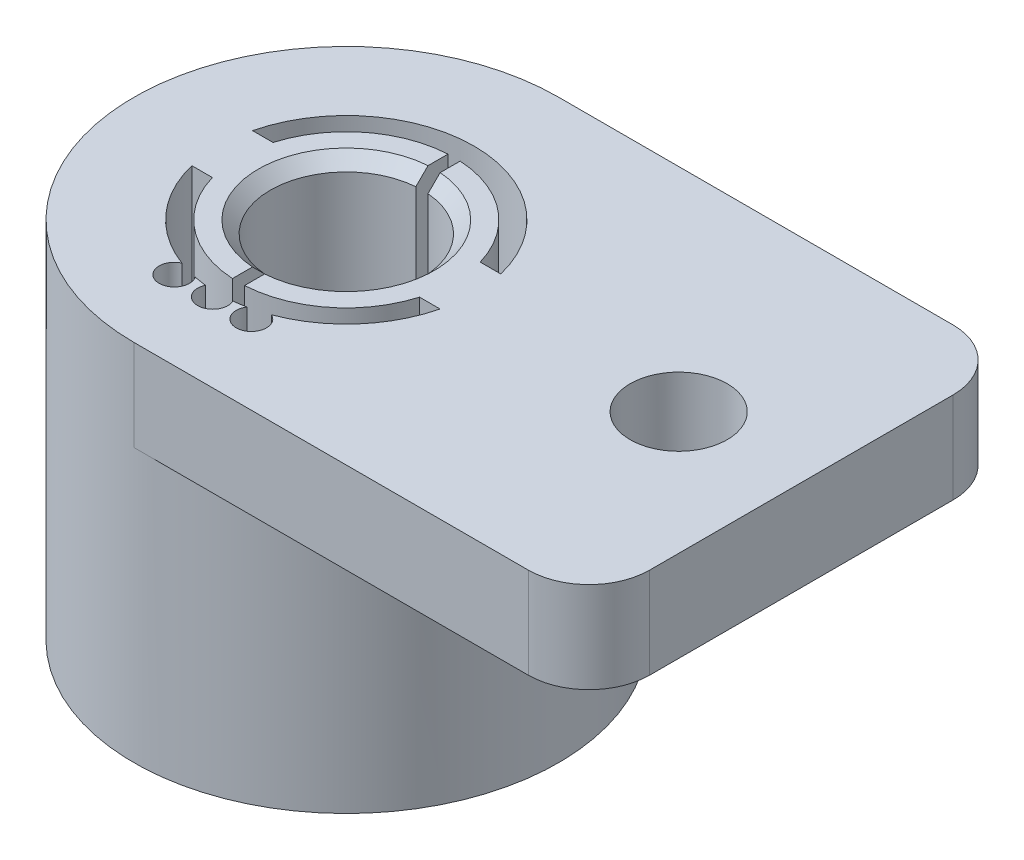
from build123d import *

# Parameters (mm, degrees)
SKETCH_1_R                  = 7
EXTRUDE_1_DEPTH             = 10
EXTRUDE_2_DEPTH             = 3
SKETCH_4_R                  = 2.5
CUT_EXTRUDE_1_DEPTH         = 1
CUT_EXTRUDE_1_DEPTH_BACK    = 14
SKETCH_6_R                  = 7
SKETCH_6_R_2                = 5.585510808
CUT_EXTRUDE_3_DEPTH         = 1
CUT_EXTRUDE_6_DEPTH         = 1
CUT_EXTRUDE_6_DEPTH_BACK    = 14
SKETCH_8_R                  = 0.5
CUT_EXTRUDE_1254_DEPTH      = 1
CUT_EXTRUDE_1254_DEPTH_BACK = 14
SKETCH_9_W                  = 4.5
SKETCH_9_H                  = 1.993168192
TSSOP_DEPTH                 = 2
FILLET_1_R                  = 2
SKETCH_10_R                 = 1.6
CUT_EXTRUDE_9_DEPTH         = 11
CUT_EXTRUDE_9_DEPTH_BACK    = 4
SKETCH_11_R                 = 4.785510808
CUT_EXTRUDE_10_DEPTH        = 0.5
CHAMFER_1_SIZE              = 0.4
CHAMFER_2_SIZE              = 0.4
CHAMFER_3_SIZE              = 0.4
CHAMFER_4_SIZE              = 0.4


with BuildPart() as part:
    # Эскиз1 → Бобышка-Вытянуть1 (new body)
    with BuildSketch(Plane(origin=(0, 0, 0), x_dir=(1, 0, 0), z_dir=(0, 1, 0))):
        Circle(SKETCH_1_R)
    extrude(amount=EXTRUDE_1_DEPTH)

    # Эскиз3 → Бобышка-Вытянуть2 (add)
    with BuildSketch(Plane(origin=(0, 10, 0), x_dir=(1, 0, 0), z_dir=(0, 1, 0))):
        with BuildLine():
            Line((0, 7), (15, 7))
            Line((15, 7), (15, -7))
            Line((15, -7), (0, -7))
            ThreePointArc((0, -7), (-7, 0), (0, 7))
        make_face()
    extrude(amount=EXTRUDE_2_DEPTH)

    # Эскиз4 → Вырез-Вытянуть1 (cut, two sides)
    with BuildSketch(Plane.XZ) as cut_extrude_1_sk:
        Circle(SKETCH_4_R)
    extrude(amount=CUT_EXTRUDE_1_DEPTH, mode=Mode.SUBTRACT)
    extrude(cut_extrude_1_sk.sketch, amount=-CUT_EXTRUDE_1_DEPTH_BACK, mode=Mode.SUBTRACT)

    # Эскиз6 → Вырез-Вытянуть3 (cut)
    with BuildSketch(Plane.XZ):
        Circle(SKETCH_6_R)
        Circle(SKETCH_6_R_2, mode=Mode.SUBTRACT)
    extrude(amount=-CUT_EXTRUDE_3_DEPTH, mode=Mode.SUBTRACT)

    # Эскиз7 → Вырез-Вытянуть6 (cut, two sides)
    with BuildSketch(Plane.XZ) as cut_extrude_6_sk:
        with BuildLine():
            Line((3.414540389, 1), (4.09167532, 1))
            ThreePointArc((4.09167532, 1), (0, 4.212102435), (-4.09167532, 1))
            Line((-4.09167532, 1), (-3.414540389, 1))
            ThreePointArc((-3.414540389, 1), (-2.212426139, 2.786441573), (-0.2, 3.552335297))
            Line((-0.2, 3.552335297), (-0.2, -3.552335297))
            ThreePointArc((-0.2, -3.552335297), (-2.212426139, -2.786441573), (-3.414540389, -1))
            Line((-3.414540389, -1), (-4.09167532, -1))
            ThreePointArc((-4.09167532, -1), (0, -4.212102435), (4.09167532, -1))
            Line((4.09167532, -1), (3.414540389, -1))
            ThreePointArc((3.414540389, -1), (2.212426139, -2.786441573), (0.2, -3.552335297))
            Line((0.2, -3.552335297), (0.2, 3.552335297))
            ThreePointArc((0.2, 3.552335297), (2.212426139, 2.786441573), (3.414540389, 1))
        make_face()
    extrude(amount=CUT_EXTRUDE_6_DEPTH, mode=Mode.SUBTRACT)
    extrude(cut_extrude_6_sk.sketch, amount=-CUT_EXTRUDE_6_DEPTH_BACK, mode=Mode.SUBTRACT)

    # Эскиз8 → Cut-Extrude 1254 (cut, two sides)
    with BuildSketch(Plane.XZ) as cut_extrude_1254_sk:
        with Locations((0, 4.4)):
            Circle(SKETCH_8_R)
        with Locations((1.27, 4.4)):
            Circle(SKETCH_8_R)
        with Locations((-1.27, 4.4)):
            Circle(SKETCH_8_R)
    extrude(amount=CUT_EXTRUDE_1254_DEPTH, mode=Mode.SUBTRACT)
    extrude(cut_extrude_1254_sk.sketch, amount=-CUT_EXTRUDE_1254_DEPTH_BACK, mode=Mode.SUBTRACT)

    # Эскиз9 → Вырез под TSSOP (cut)
    with BuildSketch(Plane.XZ):
        with Locations((0, 4.676972269)):
            Rectangle(SKETCH_9_W, SKETCH_9_H)
    extrude(amount=-TSSOP_DEPTH, mode=Mode.SUBTRACT)

    # Скругление1
    fillet_1_edges = [part.edges().sort_by_distance(p)[0] for p in [
        (15, 11.5, 7),
        (15, 11.5, -7),
    ]]
    fillet(fillet_1_edges, radius=FILLET_1_R)

    # Эскиз10 → Вырез-Вытянуть9 (cut, two sides)
    with BuildSketch(Plane.XZ.offset(-10)) as cut_extrude_9_sk:
        with Locations((10.956298859, 0)):
            Circle(SKETCH_10_R)
    extrude(amount=CUT_EXTRUDE_9_DEPTH, mode=Mode.SUBTRACT)
    extrude(cut_extrude_9_sk.sketch, amount=-CUT_EXTRUDE_9_DEPTH_BACK, mode=Mode.SUBTRACT)

    # Эскиз11 → Вырез-Вытянуть10 (cut)
    with BuildSketch(Plane.XZ):
        Circle(SKETCH_11_R)
    extrude(amount=-CUT_EXTRUDE_10_DEPTH, mode=Mode.SUBTRACT)

    # Фаска1
    chamfer_1_edges = [part.edges().sort_by_distance(p)[0] for p in [
        (-3.052092042, 0, -4.677891101),
    ]]
    chamfer(chamfer_1_edges, length=CHAMFER_1_SIZE)

    # Фаска2
    chamfer_2_edges = [part.edges().sort_by_distance(p)[0] for p in [
        (1.837117307, 0.5, -1.695582496),
    ]]
    chamfer(chamfer_2_edges, length=CHAMFER_2_SIZE)

    # Фаска3
    chamfer_3_edges = [part.edges().sort_by_distance(p)[0] for p in [
        (1.837117307, 13, -1.695582496),
        (-2.5, 13, 0),
    ]]
    chamfer(chamfer_3_edges, length=CHAMFER_3_SIZE)

    # Фаска4
    chamfer_4_edges = [part.edges().sort_by_distance(p)[0] for p in [
        (-2.5, 0.5, 0),
    ]]
    chamfer(chamfer_4_edges, length=CHAMFER_4_SIZE)


solid = part.part
